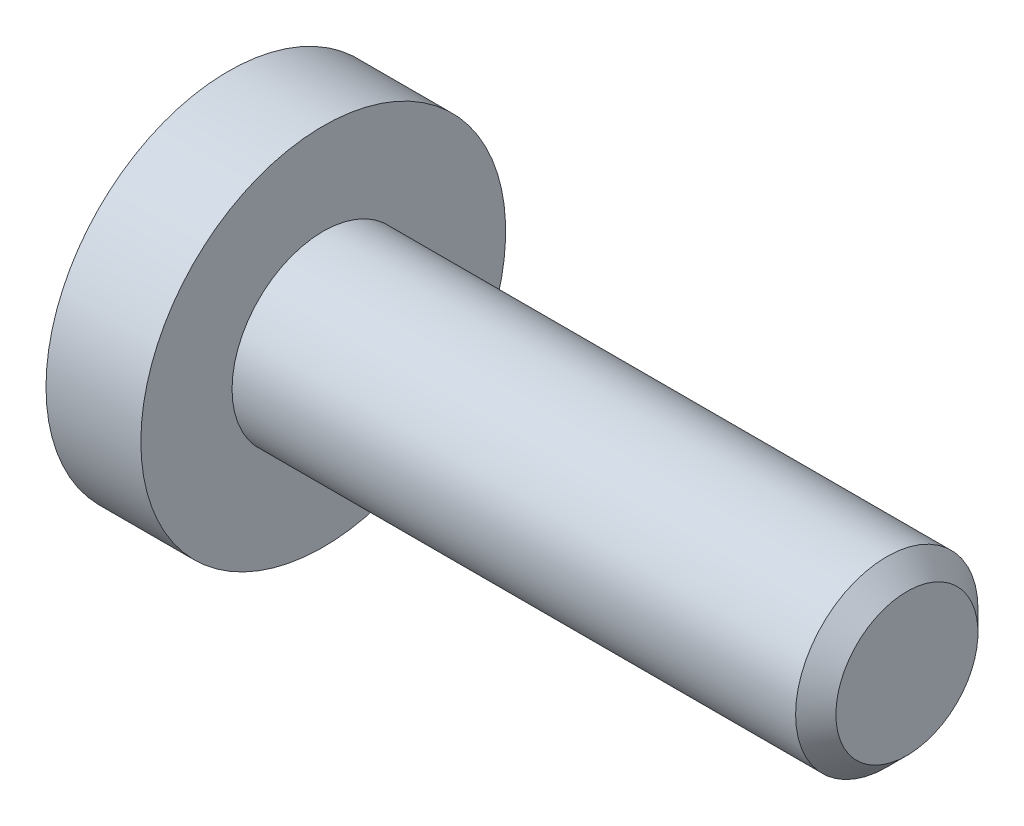
from build123d import *

# Parameters (mm, degrees)
ENL_V_MAT_EXTRU_1_DEPTH = 1.5


with BuildPart() as part:
    # Esquisse1 → Révolution1 (revolve)
    with BuildSketch(Plane(origin=(0, 0, 0), x_dir=(1, 0, 0), z_dir=(0, 1, 0))):
        Polygon((-1.3, 0), (-1.3, 2.5), (0, 2.5), (0, 1.25), (7.724, 1.25), (8, 0.974), (8, 0), align=None)
    revolve(axis=Axis((8, 0, 0), (-1, 0, 0)))

    # Esquisse2 → Enlèvement de matière-Révolution1 (revolve, cut)
    with BuildSketch(Plane.XY):
        Polygon((-1.3, 0), (-1.3, 0.75055535), (-1.19944465, 0.65), (0.2, 0.65), (0.575277675, 0), align=None)
    revolve(axis=Axis((0.575277675, 0, 0), (-1, 0, 0)), mode=Mode.SUBTRACT)

    # Esquisse3 → Enlèv. mat.-Extru.1 (cut)
    with BuildSketch(Plane(origin=(-1.3, 0, 0), x_dir=(0, 0, -1), z_dir=(1, 0, 0))):
        Polygon((-0.65, 0.375277675), (-0.65, -0.375277675), (0, -0.75055535), (0.65, -0.375277675), (0.65, 0.375277675), (0, 0.75055535), align=None)
    extrude(amount=ENL_V_MAT_EXTRU_1_DEPTH, mode=Mode.SUBTRACT)


solid = part.part
